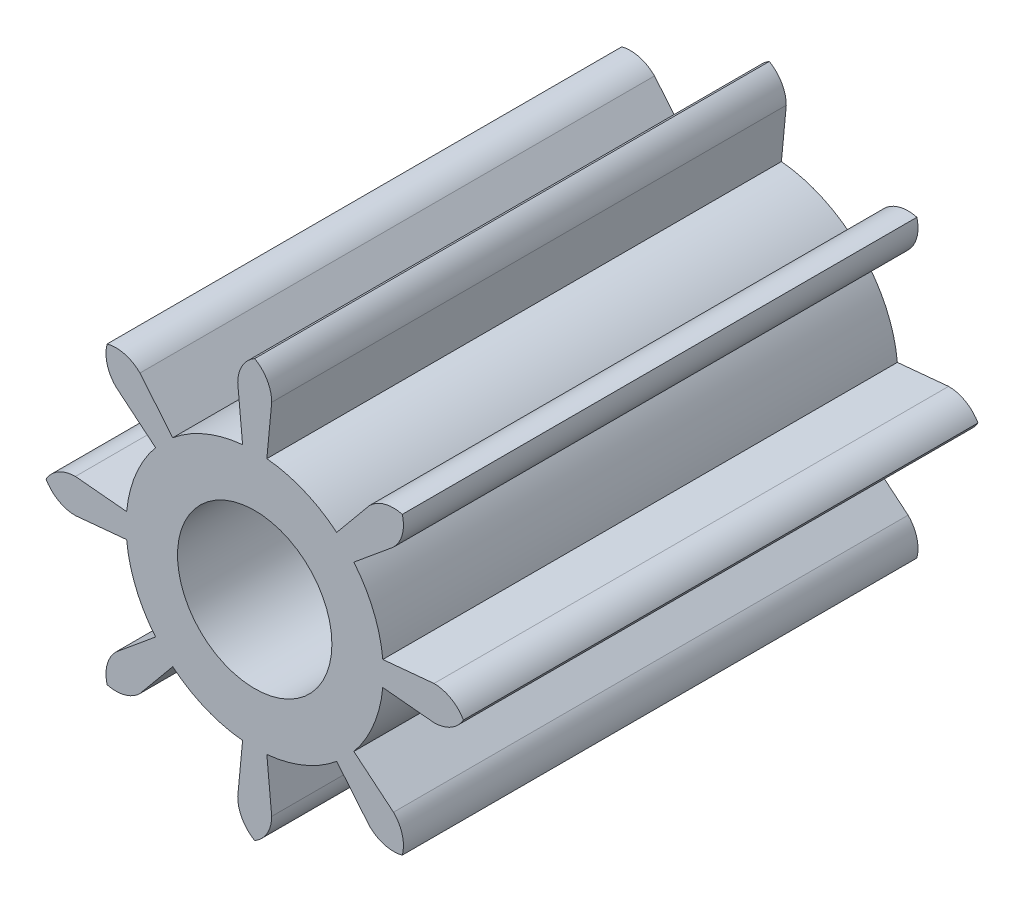
from build123d import *

# Parameters (mm, degrees)
SKETCH1_R           = 1.5
BOSS_EXTRUDE1_DEPTH = 10
CIRPATTERN1_COUNT   = 8


with BuildPart() as part:
    # Sketch1 → Boss-Extrude1 (new body)
    with BuildSketch(Plane.XY):
        with BuildLine():
            Line((-0.33, 3.484408128), (-0.235714286, 2.488862948))
            ThreePointArc((-0.235714286, 2.488862948), (0, -2.5), (0.235714286, 2.488862948))
            Line((0.235714286, 2.488862948), (0.33, 3.484408128))
            ThreePointArc((0.33, 3.484408128), (0.241576766, 3.814408128), (0, 4.055984894))
            ThreePointArc((0, 4.055984894), (-0.241576766, 3.814408128), (-0.33, 3.484408128))
        make_face()
        Circle(SKETCH1_R, mode=Mode.SUBTRACT)
    boss_extrude1 = extrude(amount=-BOSS_EXTRUDE1_DEPTH)

    # CirPattern1: Boss-Extrude1 ×8 about axis
    cirpattern1_axis = Axis((0, 0, 0), (0, 0, 1))
    for i in range(1, CIRPATTERN1_COUNT):
        add(boss_extrude1.rotate(cirpattern1_axis, i * 360 / CIRPATTERN1_COUNT))


solid = part.part
